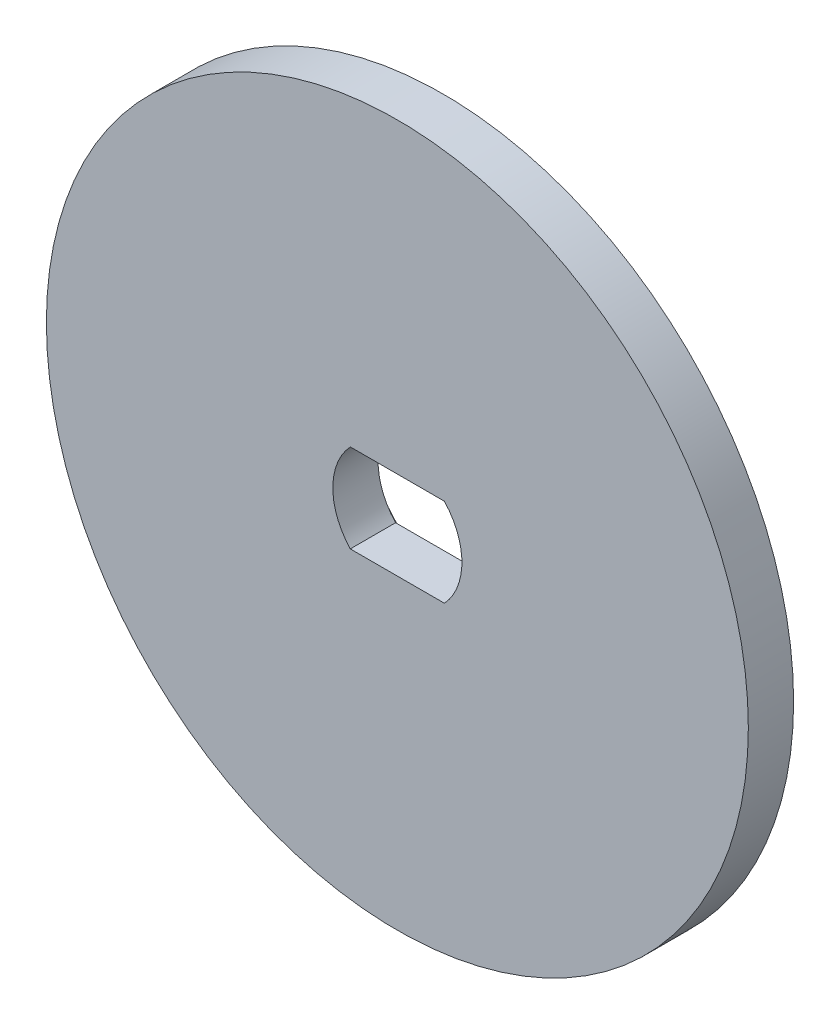
from build123d import *

# Parameters (mm, degrees)
SKETCH1_R           = 15.5
BOSS_EXTRUDE1_DEPTH = 2
BOSS_EXTRUDE2_DEPTH = 1.9
CIRPATTERN1_COUNT   = 5
CUT_EXTRUDE2_DEPTH  = 4.9


with BuildPart() as part:
    # Sketch1 → Boss-Extrude1 (new body)
    with BuildSketch(Plane.XY):
        Circle(SKETCH1_R)
    extrude(amount=BOSS_EXTRUDE1_DEPTH)

    # Sketch2 → Boss-Extrude2 (add)
    with BuildSketch(Plane(origin=(0, 0, 0), x_dir=(-1, 0, 0), z_dir=(0, 0, -1))):
        with BuildLine():
            Line((-7.817353518, 8.129035943), (-3.552701535, 4.927044661))
            ThreePointArc((-3.552701535, 4.927044661), (-3.081541521, 4.749426556), (-2.588715364, 4.852685109))
            ThreePointArc((-2.588715364, 4.852685109), (-1.571286021, 5.27077416), (-0.491007267, 5.478039053))
            ThreePointArc((-0.491007267, 5.478039053), (-0.022087339, 5.66148946), (0.274905404, 6.068103848))
            Line((0.274905404, 6.068103848), (2.090121325, 11.082582471))
            ThreePointArc((2.090121325, 11.082582471), (2.007658151, 11.864965509), (1.341576089, 12.283603874))
            ThreePointArc((1.341576089, 12.283603874), (-3.530150602, 11.841654752), (-7.848632729, 9.543883635))
            ThreePointArc((-7.848632729, 9.543883635), (-8.176755455, 8.82885995), (-7.817353518, 8.129035943))
        make_face()
    boss_extrude2 = extrude(amount=BOSS_EXTRUDE2_DEPTH)

    # CirPattern1: Boss-Extrude2 ×5 about axis
    cirpattern1_axis = Axis((0, 0, 0), (0, 0, 1))
    for i in range(1, CIRPATTERN1_COUNT):
        add(boss_extrude2.rotate(cirpattern1_axis, i * 360 / CIRPATTERN1_COUNT))

    # Sketch5 → Cut-Extrude2 (cut, through all)
    with BuildSketch(Plane.XY.offset(2)):
        with BuildLine():
            Line((-2.078460969, 1.95), (2.078460969, 1.95))
            ThreePointArc((2.078460969, 1.95), (2.85, 0), (2.078460969, -1.95))
            Line((2.078460969, -1.95), (-2.078460969, -1.95))
            ThreePointArc((-2.078460969, -1.95), (-2.85, 0), (-2.078460969, 1.95))
        make_face()
    extrude(amount=-CUT_EXTRUDE2_DEPTH, mode=Mode.SUBTRACT)


solid = part.part
